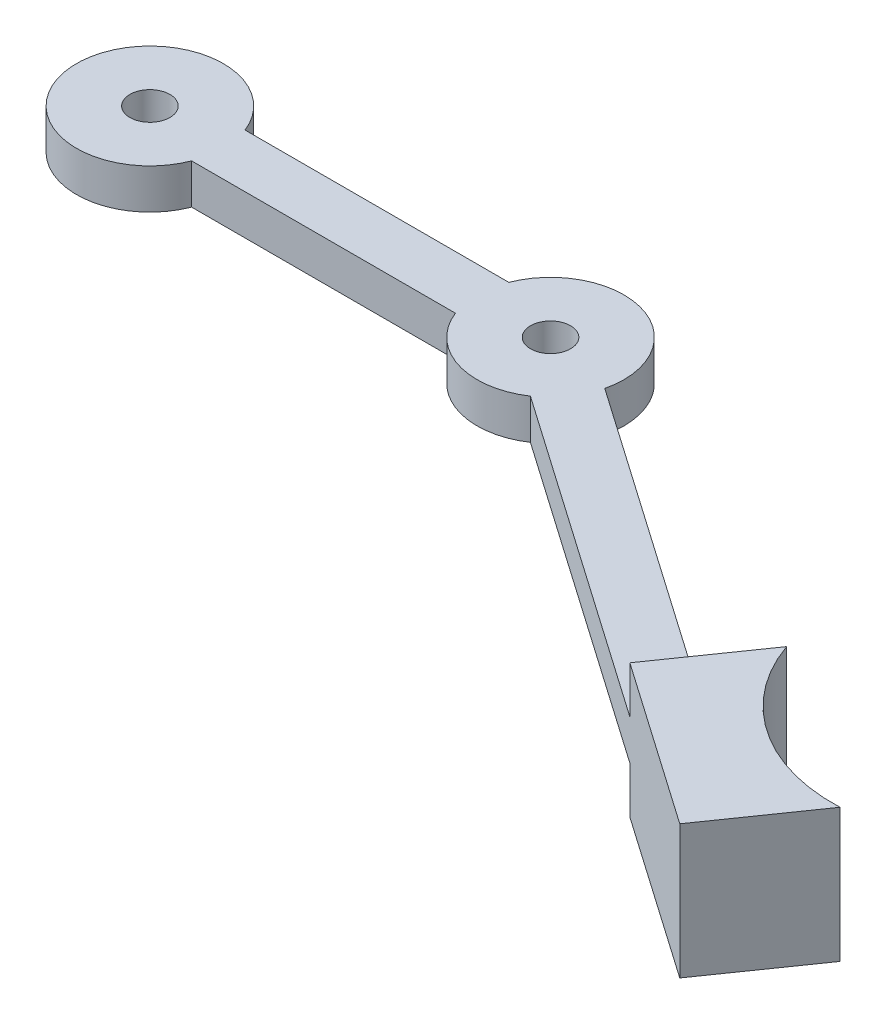
from build123d import *

# Parameters (mm, degrees)
SKETCH1_R                = 1.5
BOSS_EXTRUDE1_DEPTH      = 1.5
BOSS_EXTRUDE1_DEPTH_BACK = 1.5
BOSS_EXTRUDE2_DEPTH      = 5
BOSS_EXTRUDE2_DEPTH_BACK = 5


with BuildPart() as part:
    # Sketch1 → Boss-Extrude1 (new body, two sides)
    with BuildSketch(Plane(origin=(0, 0, 0), x_dir=(1, 0, 0), z_dir=(0, 1, 0))) as boss_extrude1_sk:
        with BuildLine():
            ThreePointArc((5.123475383, 2), (-5.5, 0), (5.123475383, -2))
            Line((5.123475383, -2), (24.876524617, -2))
            ThreePointArc((24.876524617, -2), (28.352990157, -5.247605032), (33.061732187, -4.569003832))
            Line((33.061732187, -4.569003832), (57.57995609, -21.641303613))
            Line((57.57995609, -21.641303613), (59.865670376, -18.358696387))
            Line((59.865670376, -18.358696387), (35.347446472, -1.286396606))
            ThreePointArc((35.347446472, -1.286396606), (31.647009843, 5.247605032), (24.876524617, 2))
            Line((24.876524617, 2), (5.123475383, 2))
        make_face()
        Circle(SKETCH1_R, mode=Mode.SUBTRACT)
        with Locations((30, 0)):
            Circle(SKETCH1_R, mode=Mode.SUBTRACT)
    extrude(amount=BOSS_EXTRUDE1_DEPTH)
    extrude(boss_extrude1_sk.sketch, amount=-BOSS_EXTRUDE1_DEPTH_BACK)

    # Sketch2 → Boss-Extrude2 (add, two sides)
    with BuildSketch(Plane(origin=(0, 0, 0), x_dir=(1, 0, 0), z_dir=(0, 1, 0))) as boss_extrude2_sk:
        Polygon((59.865670376, -18.358696387), (57.57995609, -21.641303613), (69.88973319, -30.212732185), (72.175447475, -26.930124958), align=None)
        with BuildLine():
            Line((62.399646215, -14.719550648), (59.865670376, -18.358696387))
            Line((59.865670376, -18.358696387), (72.175447475, -26.930124958))
            Line((72.175447475, -26.930124958), (74.81330558, -23.141789675))
            ThreePointArc((74.81330558, -23.141789675), (67.212824585, -20.984792896), (62.399646215, -14.719550648))
        make_face()
    extrude(amount=BOSS_EXTRUDE2_DEPTH)
    extrude(boss_extrude2_sk.sketch, amount=-BOSS_EXTRUDE2_DEPTH_BACK)


solid = part.part
